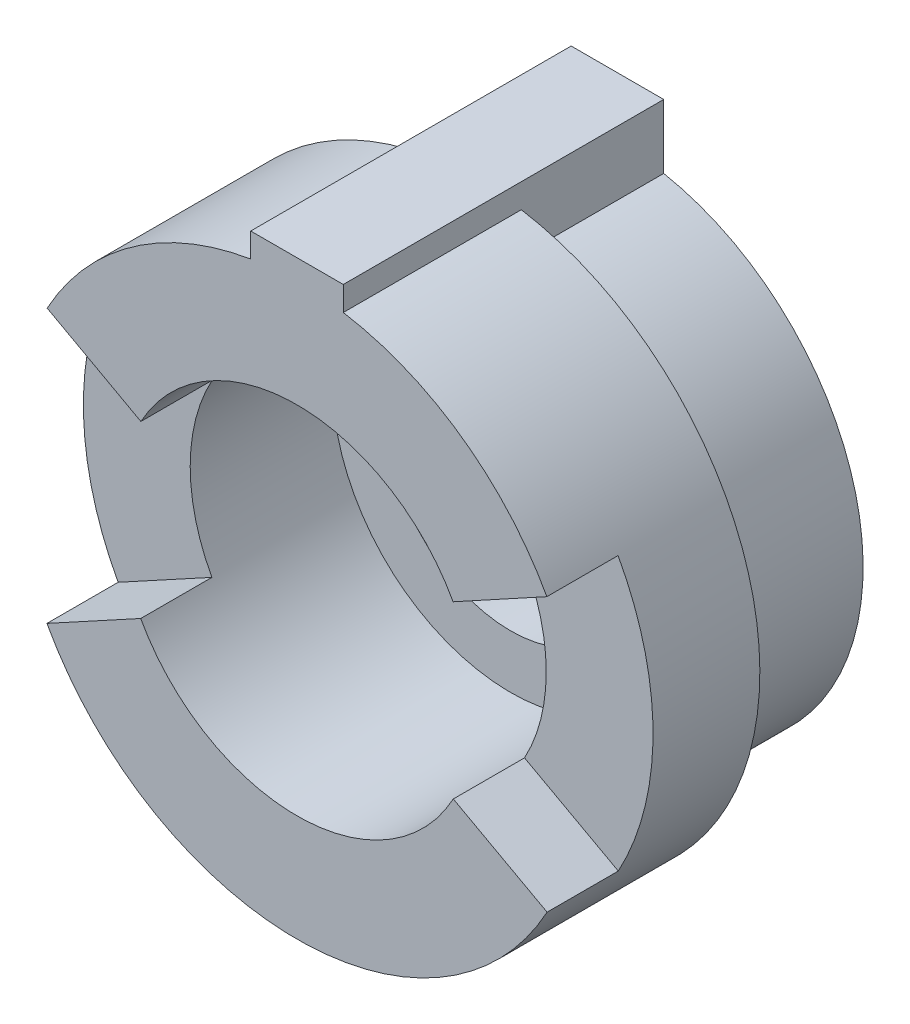
from build123d import *

# Parameters (mm, degrees)
SKETCH1_R                = 8
SKETCH1_R_2              = 3.5
BOSS_EXTRUDE1_DEPTH      = 3
SKETCH2_R                = 8
SKETCH2_R_2              = 5
BOSS_EXTRUDE2_DEPTH      = 6
WRAP3_SECTION_W          = 4
WRAP3_SECTION_H          = 2
WRAP3_ANGLE              = 57.295779513
WRAP3_SECTOR_2_SECTION_W = 4
WRAP3_SECTOR_2_SECTION_H = 2
WRAP3_SECTOR_2_ANGLE     = 57.295779513
CUT_EXTRUDE1_DEPTH       = 4
BOSS_EXTRUDE3_DEPTH      = 9


with BuildPart() as part:
    # Sketch1 → Boss-Extrude1 (new body)
    with BuildSketch(Plane.XY):
        Circle(SKETCH1_R)
        Circle(SKETCH1_R_2, mode=Mode.SUBTRACT)
    extrude(amount=BOSS_EXTRUDE1_DEPTH)

    # Sketch2 → Boss-Extrude2 (add)
    with BuildSketch(Plane.XY.offset(3)):
        Circle(SKETCH2_R)
        Circle(SKETCH2_R_2, mode=Mode.SUBTRACT)
    extrude(amount=BOSS_EXTRUDE2_DEPTH)

    # Wrap3 section (on wrap section) → Wrap3 (revolve, cut)
    with BuildSketch(Plane(origin=(0, 0, 0), x_dir=(-0.8779640629990781, -0.4787265441587198, 0), z_dir=(0.4787265441587198, -0.8779640629990781, 0))):
        with Locations((6, -8)):
            Rectangle(WRAP3_SECTION_W, WRAP3_SECTION_H)
    revolve(axis=Axis((0, 0, 0), (0, 0, -1)), revolution_arc=WRAP3_ANGLE, mode=Mode.SUBTRACT)

    # Wrap3 sector 2 section (on wrap section) → Wrap3 sector 2 (revolve, cut)
    with BuildSketch(Plane(origin=(0, 0, 0), x_dir=(0.8772005042746819, 0.4801242290285337, 0), z_dir=(-0.4801242290285337, 0.8772005042746819, 0))):
        with Locations((6, -8)):
            Rectangle(WRAP3_SECTOR_2_SECTION_W, WRAP3_SECTOR_2_SECTION_H)
    revolve(axis=Axis((0, 0, 0), (0, 0, -1)), revolution_arc=WRAP3_SECTOR_2_ANGLE, mode=Mode.SUBTRACT)

    # Sketch5 → Cut-Extrude1 (cut)
    with BuildSketch(Plane(origin=(0, 0, 0), x_dir=(-1, 0, 0), z_dir=(0, 0, -1))):
        with BuildLine():
            Line((-1.3, 6.776429738), (-1.3, 7.893668349))
            ThreePointArc((-1.3, 7.893668349), (0, -8), (1.3, 7.893668349))
            Line((1.3, 7.893668349), (1.3, 6.776429738))
            ThreePointArc((1.3, 6.776429738), (0, -6.9), (-1.3, 6.776429738))
        make_face()
    extrude(amount=-CUT_EXTRUDE1_DEPTH, mode=Mode.SUBTRACT)

    # Sketch6 → Boss-Extrude3 (add)
    with BuildSketch(Plane(origin=(0, 0, 0), x_dir=(-1, 0, 0), z_dir=(0, 0, -1))):
        with BuildLine():
            Line((-1.3, 7.797149396), (-1.3, 8.576429738))
            Line((-1.3, 8.576429738), (1.3, 8.576429738))
            Line((1.3, 8.576429738), (1.3, 7.797149396))
            ThreePointArc((1.3, 7.797149396), (0, 7.903481047), (-1.3, 7.797149396))
        make_face()
    extrude(amount=-BOSS_EXTRUDE3_DEPTH)


solid = part.part
